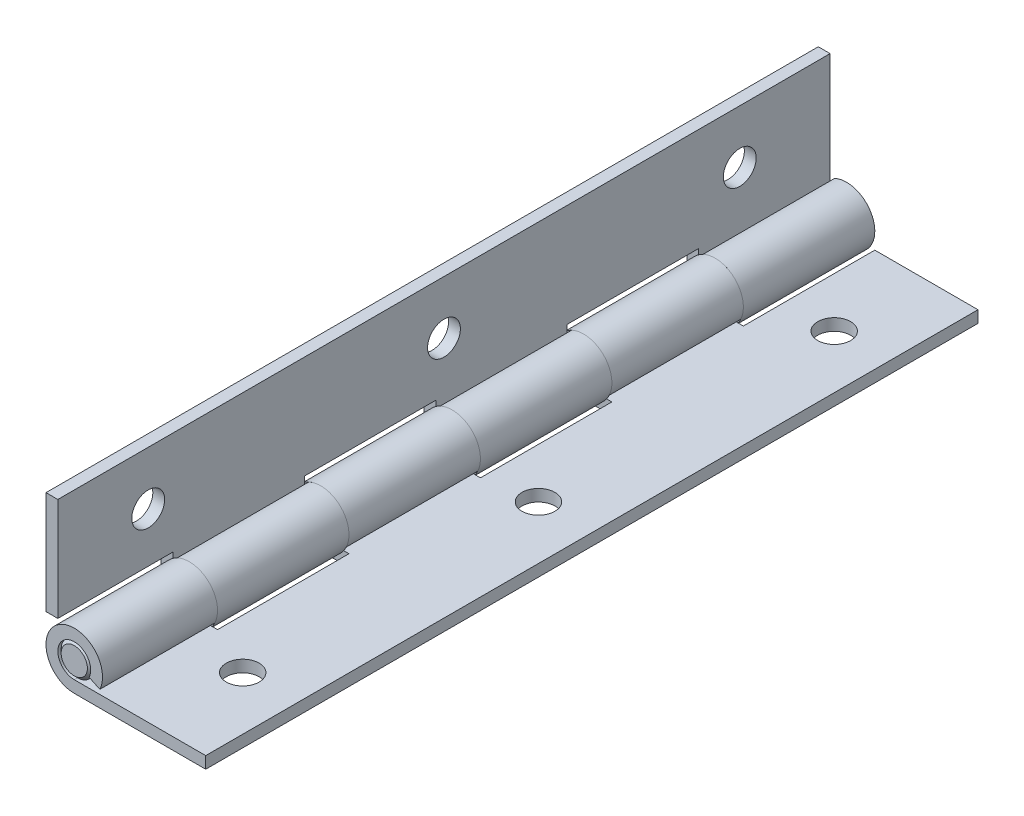
from build123d import *

# Parameters (mm, degrees)
EXTRUDE1_DEPTH          = 74.6125
SKETCH3_W               = 10.922
SKETCH3_H               = 25.4
CUT_EXTRUDE1_DEPTH      = 25.4
LPATTERN1_COUNT         = 3
LPATTERN1_PITCH         = 50.8
EXTRUDE2_DEPTH          = 25.4
LPATTERN3_COUNT         = 3
LPATTERN3_PITCH         = 50.8
SKETCH6_W               = 19.9136
SKETCH6_H               = 2.286
EXTRUDE5_DEPTH          = 149.225
SKETCH7_R               = 3.175
EXTRUDE4_DEPTH          = 74.6125
CHAMFER1_SIZE           = 0.635
SKETCH12_R              = 3.175
CUT_EXTRUDE2_DEPTH      = 9.636
CUT_EXTRUDE2_DEPTH_BACK = 3.286
BODY_MOVE_COPY1_ANGLE   = 45
BODY_MOVE_COPY2_ANGLE   = 45


with BuildPart() as part:
    # Sketch2 → Extrude1 (new body, symmetric)
    with BuildSketch(Plane.XY):
        with BuildLine():
            Line((25.4, -3.175), (25.4, -5.461))
            Line((25.4, -5.461), (0, -5.461))
            ThreePointArc((0, -5.461), (-2.934193161, 4.605760686), (4.949346825, -2.307918327))
            Line((4.949346825, -2.307918327), (2.877527224, -1.341812981))
            ThreePointArc((2.877527224, -1.341812981), (-1.705926257, 2.67776784), (0, -3.175))
            Line((0, -3.175), (25.4, -3.175))
        make_face()
    extrude(amount=EXTRUDE1_DEPTH, both=True)

    # Sketch3 → Cut-Extrude1 (cut, symmetric)
    with BuildSketch(Plane(origin=(0, -3.175, 0), x_dir=(1, 0, 0), z_dir=(0, 1, 0))):
        with Locations((0, 61.9125)):
            Rectangle(SKETCH3_W, SKETCH3_H)
    cut_extrude1 = extrude(amount=CUT_EXTRUDE1_DEPTH, both=True, mode=Mode.SUBTRACT)

    # LPattern1: Cut-Extrude1 ×3
    with Locations(*[(0, 0, i * LPATTERN1_PITCH) for i in range(1, LPATTERN1_COUNT)]):
        add(cut_extrude1, mode=Mode.SUBTRACT)


with BuildPart() as body_2:
    # Sketch5 → Extrude2 (new body)
    with BuildSketch(Plane(origin=(0, 0, -74.6125), x_dir=(-1, 0, 0), z_dir=(0, 0, -1))):
        with BuildLine():
            Line((0, -3.175), (25.4, -3.175))
            Line((25.4, -3.175), (25.4, -5.461))
            Line((25.4, -5.461), (0, -5.461))
            ThreePointArc((0, -5.461), (-2.934193161, 4.605760686), (4.949346825, -2.307918327))
            Line((4.949346825, -2.307918327), (2.877527224, -1.341812981))
            ThreePointArc((2.877527224, -1.341812981), (-1.705926257, 2.67776784), (0, -3.175))
        make_face()
    extrude(amount=-EXTRUDE2_DEPTH)


with BuildPart() as lpattern3_1:
    # LPattern3: pattern copy
    add(body_2.part.moved(Location(Vector(0, 0, 1) * (1 * LPATTERN3_PITCH))))


with BuildPart() as lpattern3_2:
    # LPattern3: pattern copy
    add(body_2.part.moved(Location(Vector(0, 0, 1) * (2 * LPATTERN3_PITCH))))


with BuildPart() as body_2_1:
    add(body_2.part)

    add(lpattern3_1.part)  # Extrude5 merges LPattern3_1

    add(lpattern3_2.part)  # Extrude5 merges LPattern3_2
    # Sketch6 → Extrude5 (add)
    with BuildSketch(Plane(origin=(0, 0, -74.6125), x_dir=(-1, 0, 0), z_dir=(0, 0, -1))):
        with Locations((15.4432, -4.318)):
            Rectangle(SKETCH6_W, SKETCH6_H)
    extrude(amount=-EXTRUDE5_DEPTH)


with BuildPart() as body_3:
    # Sketch7 → Extrude4 (new body, symmetric)
    with BuildSketch(Plane.XY):
        Circle(SKETCH7_R)
    extrude(amount=EXTRUDE4_DEPTH, both=True)

    # Chamfer1
    chamfer1_edges = [body_3.edges().sort_by_distance(p)[0] for p in [
        (-3.175, 0, -74.6125),
        (-3.175, 0, 74.6125),
    ]]
    chamfer(chamfer1_edges, length=CHAMFER1_SIZE)


with BuildPart() as cut_extrude2_tool:
    # Sketch12 → Cut-Extrude2 (new body, two sides)
    with BuildSketch(Plane(origin=(0, -3.175, 0), x_dir=(1, 0, 0), z_dir=(0, 1, 0))) as cut_extrude2_sk:
        with Locations((-15.08125, 57.15)):
            Circle(SKETCH12_R)
        with Locations((-15.08125, 0)):
            Circle(SKETCH12_R)
        with Locations((-15.08125, -57.15)):
            Circle(SKETCH12_R)
        with Locations((15.08125, 0)):
            Circle(SKETCH12_R)
        with Locations((15.08125, 57.15)):
            Circle(SKETCH12_R)
        with Locations((15.08125, -57.15)):
            Circle(SKETCH12_R)
    extrude(amount=CUT_EXTRUDE2_DEPTH)
    extrude(cut_extrude2_sk.sketch, amount=-CUT_EXTRUDE2_DEPTH_BACK)


with BuildPart() as part_1:
    add(part.part)

    # Cut-Extrude2: cut by cut_extrude2_tool
    add(cut_extrude2_tool.part, mode=Mode.SUBTRACT)


with BuildPart() as body_2_2:
    add(body_2_1.part)

    # Cut-Extrude2: cut by cut_extrude2_tool
    add(cut_extrude2_tool.part, mode=Mode.SUBTRACT)


with BuildPart() as body_2_3:
    # Body-Move_Copy1: moved
    add(body_2_2.part.rotate(Axis((0, 0, 0), (0, 0, -1)), BODY_MOVE_COPY1_ANGLE))


with BuildPart() as body_2_4:
    # Body-Move_Copy2: moved
    add(body_2_3.part.rotate(Axis((0, 0, 0), (0, 0, -1)), BODY_MOVE_COPY2_ANGLE))


solid = Compound([body_3.part, part_1.part, body_2_4.part])
